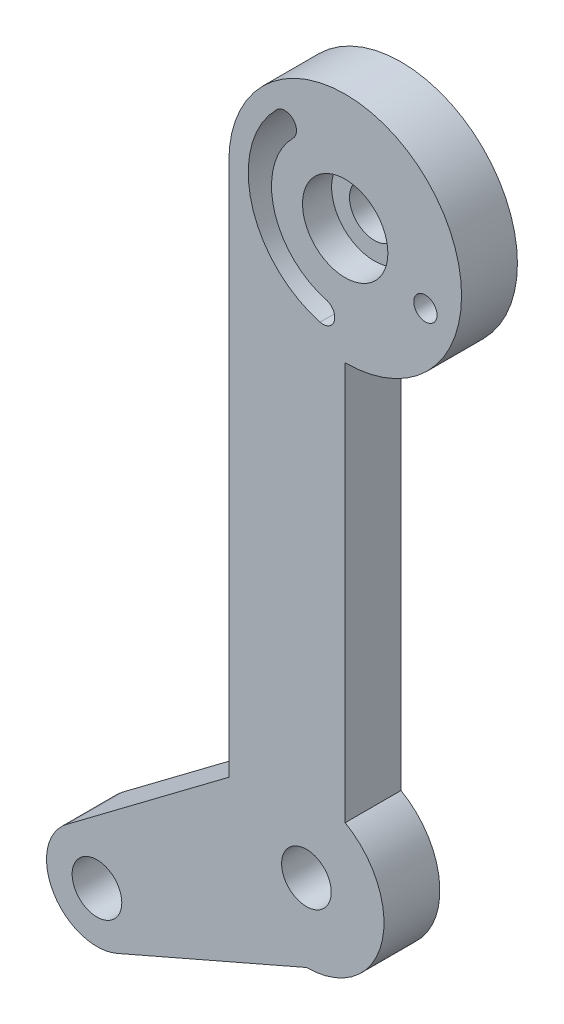
from build123d import *

# Parameters (mm, degrees)
SKETCH1_R           = 1.6
BOSS_EXTRUDE1_DEPTH = 3.6
SKETCH2_R           = 0.75
CUT_EXTRUDE1_DEPTH  = 4.6
SKETCH4_R           = 2.75
CUT_EXTRUDE3_DEPTH  = 1.875


with BuildPart() as part:
    # Sketch1 → Boss-Extrude1 (new body)
    with BuildSketch(Plane.XY):
        with BuildLine():
            Line((-5, 37.5), (-5, 3.117408991))
            Line((-5, 3.117408991), (-15.45246273, -4.737424277))
            ThreePointArc((-15.45246273, -4.737424277), (-16.30801025, -8.97190619), (-12.202106424, -10.31516804))
            Line((-12.202106424, -10.31516804), (0, -5))
            ThreePointArc((0, -5), (4.829629131, -1.294095226), (2.5, 4.330127019))
            Line((2.5, 4.330127019), (2.5, 30))
            ThreePointArc((2.5, 30), (7.803300859, 42.803300859), (-5, 37.5))
        make_face()
        Circle(SKETCH1_R, mode=Mode.SUBTRACT)
        with Locations((-13.5, -7.335575406)):
            Circle(SKETCH1_R, mode=Mode.SUBTRACT)
        with Locations((2.5, 37.5)):
            Circle(SKETCH1_R, mode=Mode.SUBTRACT)
    extrude(amount=BOSS_EXTRUDE1_DEPTH)

    # Sketch2 → Cut-Extrude1 (cut, through all)
    with BuildSketch(Plane.XY.offset(3.6)):
        with Locations((7.668309414, 35.618889212)):
            Circle(SKETCH2_R)
        with BuildLine():
            ThreePointArc((-0.858757211, 40.858757211), (-0.858757211, 41.919417382), (-1.919417382, 41.919417382))
            ThreePointArc((-1.919417382, 41.919417382), (-3.537036414, 35.882380968), (0.882380968, 31.462963586))
            ThreePointArc((0.882380968, 31.462963586), (1.800939622, 31.993293672), (1.270609536, 32.911852325))
            ThreePointArc((1.270609536, 32.911852325), (-2.088147675, 36.270609536), (-0.858757211, 40.858757211))
        make_face()
    extrude(amount=-CUT_EXTRUDE1_DEPTH, mode=Mode.SUBTRACT)

    # Sketch4 → Cut-Extrude3 (cut)
    with BuildSketch(Plane.XY.offset(3.6)):
        with Locations((2.5, 37.5)):
            Circle(SKETCH4_R)
    extrude(amount=-CUT_EXTRUDE3_DEPTH, mode=Mode.SUBTRACT)


solid = part.part
